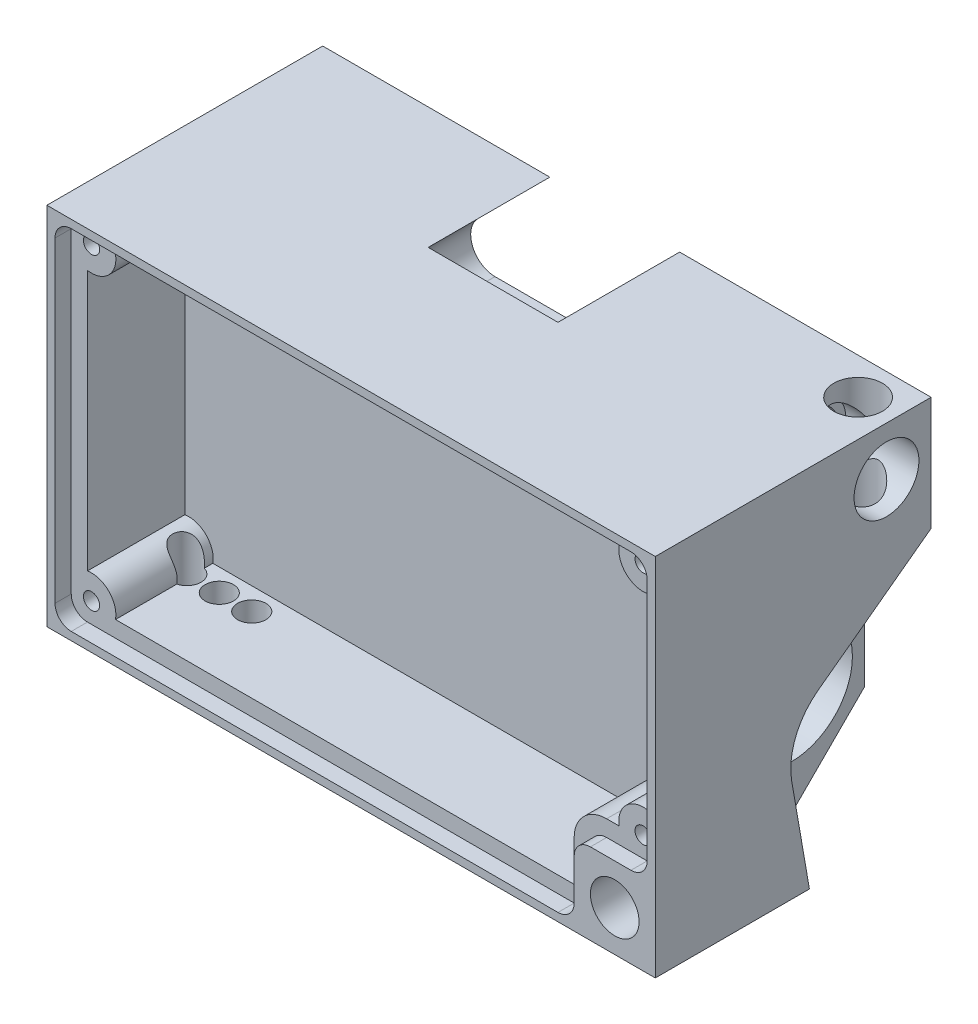
from build123d import *

# Parameters (mm, degrees)
BOSS_EXTRUDE1_DEPTH = 75
CUT_EXTRUDE1_DEPTH  = 8.2
CUT_EXTRUDE2_DEPTH  = 15
FILLET1_R           = 3
SKETCH5_R           = 4
CUT_EXTRUDE3_DEPTH  = 9
CUT_EXTRUDE4_REACH  = 47
SKETCH6_R           = 3
CUT_EXTRUDE5_REACH  = 36
SKETCH7_R           = 3
CUT_EXTRUDE7_REACH  = 47
SKETCH10_R          = 2.5
CUT_EXTRUDE8_REACH  = 68
SKETCH11_R          = 3
CUT_EXTRUDE10_DEPTH = 2
FILLET3_R           = 2
CUT_EXTRUDE11_DEPTH = 12
CUT_EXTRUDE12_REACH = 47
SKETCH16_R          = 1.75
SKETCH17_R          = 1
CUT_EXTRUDE13_DEPTH = 5
SKETCH8_R           = 7.5
CUT_EXTRUDE14_DEPTH = 60


with BuildPart() as part:
    # Sketch1 → Boss-Extrude1 (new body)
    with BuildSketch(Plane(origin=(0, 0, 0), x_dir=(0, 0, -1), z_dir=(1, 0, 0))):
        Polygon((24, 0), (34, 10), (34, 45), (0, 45), (0, 0), align=None)
    extrude(amount=-BOSS_EXTRUDE1_DEPTH)

    # Sketch2 → Cut-Extrude1 (cut)
    with BuildSketch(Plane(origin=(0, 0, 0), x_dir=(0, 0, -1), z_dir=(1, 0, 0))):
        with BuildLine():
            Line((19, 0), (16.821625926, 12.584303175))
            ThreePointArc((16.821625926, 12.584303175), (17.294620228, 17.084983398), (20.058295206, 20.668549597))
            Line((20.058295206, 20.668549597), (34, 31))
            Line((34, 31), (34, 0))
            Line((34, 0), (19, 0))
        make_face()
    extrude(amount=-CUT_EXTRUDE1_DEPTH, mode=Mode.SUBTRACT)

    # Sketch3 → Cut-Extrude2 (cut)
    with BuildSketch(Plane(origin=(0, 0, -34), x_dir=(-1, 0, 0), z_dir=(0, 0, -1))):
        Polygon((31, 45), (31, 31), (61, 31), (47, 45), align=None)
    extrude(amount=-CUT_EXTRUDE2_DEPTH, mode=Mode.SUBTRACT)

    # Fillet1
    fillet1_edges = [part.edges().sort_by_distance(p)[0] for p in [
        (-61, 31, -26.5),
        (-31, 31, -26.5),
    ]]
    fillet(fillet1_edges, radius=FILLET1_R)

    # Sketch5 → Cut-Extrude3 (cut)
    with BuildSketch(Plane(origin=(0, 0, 0), x_dir=(0, 0, -1), z_dir=(1, 0, 0))):
        with Locations((28.5, 39)):
            Circle(SKETCH5_R)
    extrude(amount=-CUT_EXTRUDE3_DEPTH, mode=Mode.SUBTRACT)

    # Sketch6 → Cut-Extrude4 (cut, up to next)
    with BuildSketch(Plane(origin=(0, 45, 0), x_dir=(1, 0, 0), z_dir=(0, 1, 0)), mode=Mode.PRIVATE) as cut_extrude4_sk1:
        with Locations((-4.5, 29.5)):
            Circle(SKETCH6_R)
    cut_extrude4_tool1 = extrude(cut_extrude4_sk1.sketch, amount=-CUT_EXTRUDE4_REACH, mode=Mode.PRIVATE) & part.part
    add(cut_extrude4_tool1.solids().sort_by_distance((-4.5, 45, -29.5))[0], mode=Mode.SUBTRACT)

    # Sketch7 → Cut-Extrude5 (cut, up to next)
    with BuildSketch(Plane.XY, mode=Mode.PRIVATE) as cut_extrude5_sk1:
        with Locations((-5, 5)):
            Circle(SKETCH7_R)
    cut_extrude5_tool1 = extrude(cut_extrude5_sk1.sketch, amount=-CUT_EXTRUDE5_REACH, mode=Mode.PRIVATE) & part.part
    add(cut_extrude5_tool1.solids().sort_by_distance((-5, 5, 0))[0], mode=Mode.SUBTRACT)

    # Sketch10 → Cut-Extrude7 (cut, up to next)
    with BuildSketch(Plane(origin=(0, 45, 0), x_dir=(1, 0, 0), z_dir=(0, 1, 0)), mode=Mode.PRIVATE) as cut_extrude7_sk1:
        with Locations((-4.5, 29.5)):
            Circle(SKETCH10_R)
    cut_extrude7_tool1 = extrude(cut_extrude7_sk1.sketch, amount=-CUT_EXTRUDE7_REACH, mode=Mode.PRIVATE) & part.part
    add(cut_extrude7_tool1.solids().sort_by_distance((-4.5, 45, -29.5))[0], mode=Mode.SUBTRACT)

    # Sketch11 → Cut-Extrude8 (cut, up to next)
    with BuildSketch(Plane(origin=(-9, 0, 0), x_dir=(0, 0, -1), z_dir=(1, 0, 0)), mode=Mode.PRIVATE) as cut_extrude8_sk1:
        with Locations((28.5, 39)):
            Circle(SKETCH11_R)
    cut_extrude8_tool1 = extrude(cut_extrude8_sk1.sketch, amount=-CUT_EXTRUDE8_REACH, mode=Mode.PRIVATE) & part.part
    add(cut_extrude8_tool1.solids().sort_by_distance((-9, 39, -28.5))[0], mode=Mode.SUBTRACT)

    # Sketch13 → Cut-Extrude10 (cut)
    with BuildSketch(Plane.XY):
        Polygon((-74, 44), (-74, 1), (-10, 1), (-10, 10), (-1, 10), (-1, 44), align=None)
    extrude(amount=-CUT_EXTRUDE10_DEPTH, mode=Mode.SUBTRACT)

    # Fillet3
    fillet3_edges = [part.edges().sort_by_distance(p)[0] for p in [
        (-74, 44, -1),
        (-1, 44, -1),
        (-1, 10, -1),
        (-10, 10, -1),
        (-10, 1, -1),
        (-74, 1, -1),
    ]]
    fillet(fillet3_edges, radius=FILLET3_R)

    # Sketch14 → Cut-Extrude11 (cut)
    with BuildSketch(Plane.XY.offset(-2)):
        with BuildLine():
            ThreePointArc((-6.458039892, 12), (-5.621320344, 14.621320344), (-3, 15.458039892))
            Line((-3, 15.458039892), (-3, 38.541960108))
            ThreePointArc((-3, 38.541960108), (-5.621320344, 39.378679656), (-6.458039892, 42))
            Line((-6.458039892, 42), (-68.541960108, 42))
            ThreePointArc((-68.541960108, 42), (-68.510508432, 41.750878781), (-68.5, 41.5))
            ThreePointArc((-68.5, 41.5), (-69.563508327, 39.208712153), (-72, 38.541960108))
            Line((-72, 38.541960108), (-72, 6.458039892))
            ThreePointArc((-72, 6.458039892), (-69.563508327, 5.791287847), (-68.5, 3.5))
            ThreePointArc((-68.5, 3.5), (-68.510508432, 3.249121219), (-68.541960108, 3))
            Line((-68.541960108, 3), (-12, 3))
            Line((-12, 3), (-12, 8))
            ThreePointArc((-12, 8), (-10.828427125, 10.828427125), (-8, 12))
            Line((-8, 12), (-6.458039892, 12))
        make_face()
    extrude(amount=-CUT_EXTRUDE11_DEPTH, mode=Mode.SUBTRACT)

    # Sketch16 → Cut-Extrude12 (cut, up to next)
    with BuildSketch(Plane.XZ, mode=Mode.PRIVATE) as cut_extrude12_sk1:
        with Locations((-69, -11.25)):
            Circle(SKETCH16_R)
    cut_extrude12_tool1 = extrude(cut_extrude12_sk1.sketch, amount=-CUT_EXTRUDE12_REACH, mode=Mode.PRIVATE) & part.part
    add(cut_extrude12_tool1.solids().sort_by_distance((-69, 0, -11.25))[0], mode=Mode.SUBTRACT)
    # Sketch16 → Cut-Extrude12 (cut, up to next)
    with BuildSketch(Plane.XZ, mode=Mode.PRIVATE) as cut_extrude12_sk2:
        with Locations((-65, -11.25)):
            Circle(SKETCH16_R)
    cut_extrude12_tool2 = extrude(cut_extrude12_sk2.sketch, amount=-CUT_EXTRUDE12_REACH, mode=Mode.PRIVATE) & part.part
    add(cut_extrude12_tool2.solids().sort_by_distance((-65, 0, -11.25))[0], mode=Mode.SUBTRACT)
    # Sketch16 → Cut-Extrude12 (cut, up to next)
    with BuildSketch(Plane.XZ, mode=Mode.PRIVATE) as cut_extrude12_sk3:
        with Locations((-61, -11.25)):
            Circle(SKETCH16_R)
    cut_extrude12_tool3 = extrude(cut_extrude12_sk3.sketch, amount=-CUT_EXTRUDE12_REACH, mode=Mode.PRIVATE) & part.part
    add(cut_extrude12_tool3.solids().sort_by_distance((-61, 0, -11.25))[0], mode=Mode.SUBTRACT)

    # Sketch17 → Cut-Extrude13 (cut)
    with BuildSketch(Plane.XY.offset(-2)):
        with Locations((-71.5, 41.5)):
            Circle(SKETCH17_R)
        with Locations((-71.5, 3.5)):
            Circle(SKETCH17_R)
        with Locations((-3.5, 12.5)):
            Circle(SKETCH17_R)
        with Locations((-3.5, 41.5)):
            Circle(SKETCH17_R)
    extrude(amount=-CUT_EXTRUDE13_DEPTH, mode=Mode.SUBTRACT)

    # Sketch8 → Cut-Extrude14 (cut)
    with BuildSketch(Plane(origin=(-8.2, 0, 0), x_dir=(0, 0, -1), z_dir=(1, 0, 0))):
        with Locations((25, 14)):
            Circle(SKETCH8_R)
    extrude(amount=-CUT_EXTRUDE14_DEPTH, mode=Mode.SUBTRACT)


solid = part.part
